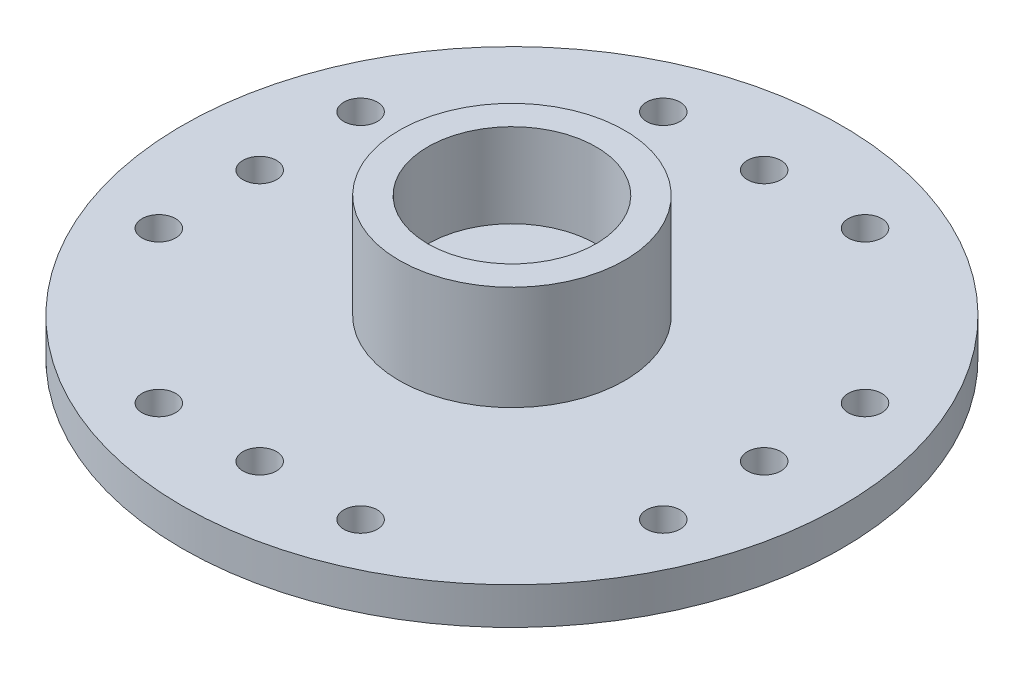
from build123d import *

# Parameters (mm, degrees)
SKETCH1_R           = 9.8
BOSS_EXTRUDE1_DEPTH = 1.1
SKETCH2_R           = 3.35
BOSS_EXTRUDE2_DEPTH = 3.1
SKETCH3_R           = 2.5
CUT_EXTRUDE1_DEPTH  = 2.5
CUT_EXTRUDE2_REACH  = 3.7
SKETCH4_R           = 1
SKETCH5_R           = 2
CUT_EXTRUDE3_DEPTH  = 0.5
SKETCH6_R           = 0.5
CUT_EXTRUDE4_DEPTH  = 5.2
CIRPATTERN1_COUNT   = 4


with BuildPart() as part:
    # Sketch1 → Boss-Extrude1 (new body)
    with BuildSketch(Plane(origin=(0, 0, 0), x_dir=(1, 0, 0), z_dir=(0, 1, 0))):
        Circle(SKETCH1_R)
    extrude(amount=BOSS_EXTRUDE1_DEPTH)

    # Sketch2 → Boss-Extrude2 (add)
    with BuildSketch(Plane(origin=(0, 1.1, 0), x_dir=(1, 0, 0), z_dir=(0, 1, 0))):
        Circle(SKETCH2_R)
    extrude(amount=BOSS_EXTRUDE2_DEPTH)

    # Sketch3 → Cut-Extrude1 (cut)
    with BuildSketch(Plane(origin=(0, 4.2, 0), x_dir=(1, 0, 0), z_dir=(0, 1, 0))):
        Circle(SKETCH3_R)
    extrude(amount=-CUT_EXTRUDE1_DEPTH, mode=Mode.SUBTRACT)

    # Sketch4 → Cut-Extrude2 (cut, up to next)
    with BuildSketch(Plane(origin=(0, 1.7, 0), x_dir=(1, 0, 0), z_dir=(0, 1, 0)), mode=Mode.PRIVATE) as cut_extrude2_sk1:
        Circle(SKETCH4_R)
    cut_extrude2_tool1 = extrude(cut_extrude2_sk1.sketch, amount=-CUT_EXTRUDE2_REACH, mode=Mode.PRIVATE) & part.part
    add(cut_extrude2_tool1.solids().sort_by_distance((0, 1.7, 0))[0], mode=Mode.SUBTRACT)

    # Sketch5 → Cut-Extrude3 (cut)
    with BuildSketch(Plane.XZ):
        Circle(SKETCH5_R)
    extrude(amount=-CUT_EXTRUDE3_DEPTH, mode=Mode.SUBTRACT)

    # Sketch6 → Cut-Extrude4 (cut, through all)
    with BuildSketch(Plane.XZ):
        with Locations((-3, 7.5)):
            Circle(SKETCH6_R)
        with Locations((0, 7.5)):
            Circle(SKETCH6_R)
        with Locations((3, 7.5)):
            Circle(SKETCH6_R)
    cut_extrude4 = extrude(amount=-CUT_EXTRUDE4_DEPTH, mode=Mode.SUBTRACT)

    # CirPattern1: Cut-Extrude4 ×4 about axis
    cirpattern1_axis = Axis((0, 0, 0), (0, 1, 0))
    for i in range(1, CIRPATTERN1_COUNT):
        add(cut_extrude4.rotate(cirpattern1_axis, i * 360 / CIRPATTERN1_COUNT), mode=Mode.SUBTRACT)


solid = part.part
